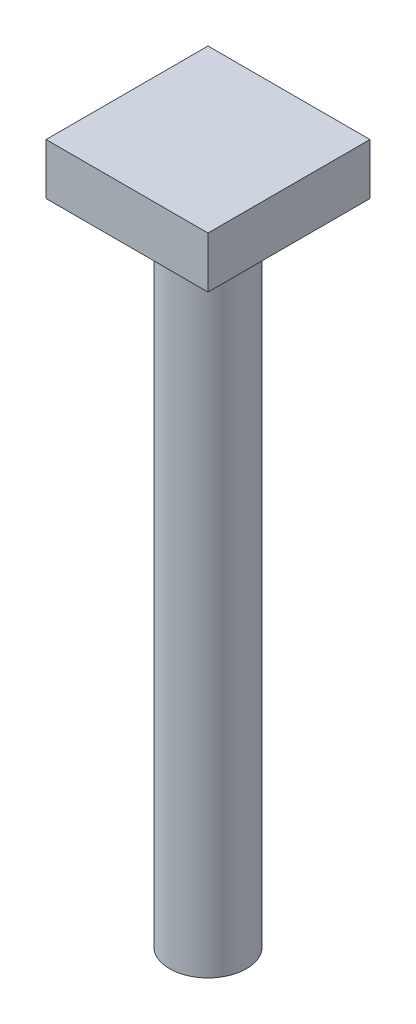
from build123d import *

# Parameters (mm, degrees)
SKETCH2_W           = 19
SKETCH2_H           = 19
BOSS_EXTRUDE1_DEPTH = 6
SKETCH3_R           = 4.5
BOSS_EXTRUDE2_DEPTH = 76


with BuildPart() as part:
    # Sketch2 → Boss-Extrude1 (new body)
    with BuildSketch(Plane(origin=(0, 0, 0), x_dir=(1, 0, 0), z_dir=(0, 1, 0))):
        Rectangle(SKETCH2_W, SKETCH2_H)
    extrude(amount=BOSS_EXTRUDE1_DEPTH)

    # Sketch3 → Boss-Extrude2 (add)
    with BuildSketch(Plane(origin=(0, 0, 0), x_dir=(-1, 0, 0), z_dir=(0, -1, 0))):
        with Locations(Location((0, 0, 0), (0, 0, 90))):  # turned: the seam where the file's is
            Circle(SKETCH3_R)
    extrude(amount=BOSS_EXTRUDE2_DEPTH)


solid = part.part
